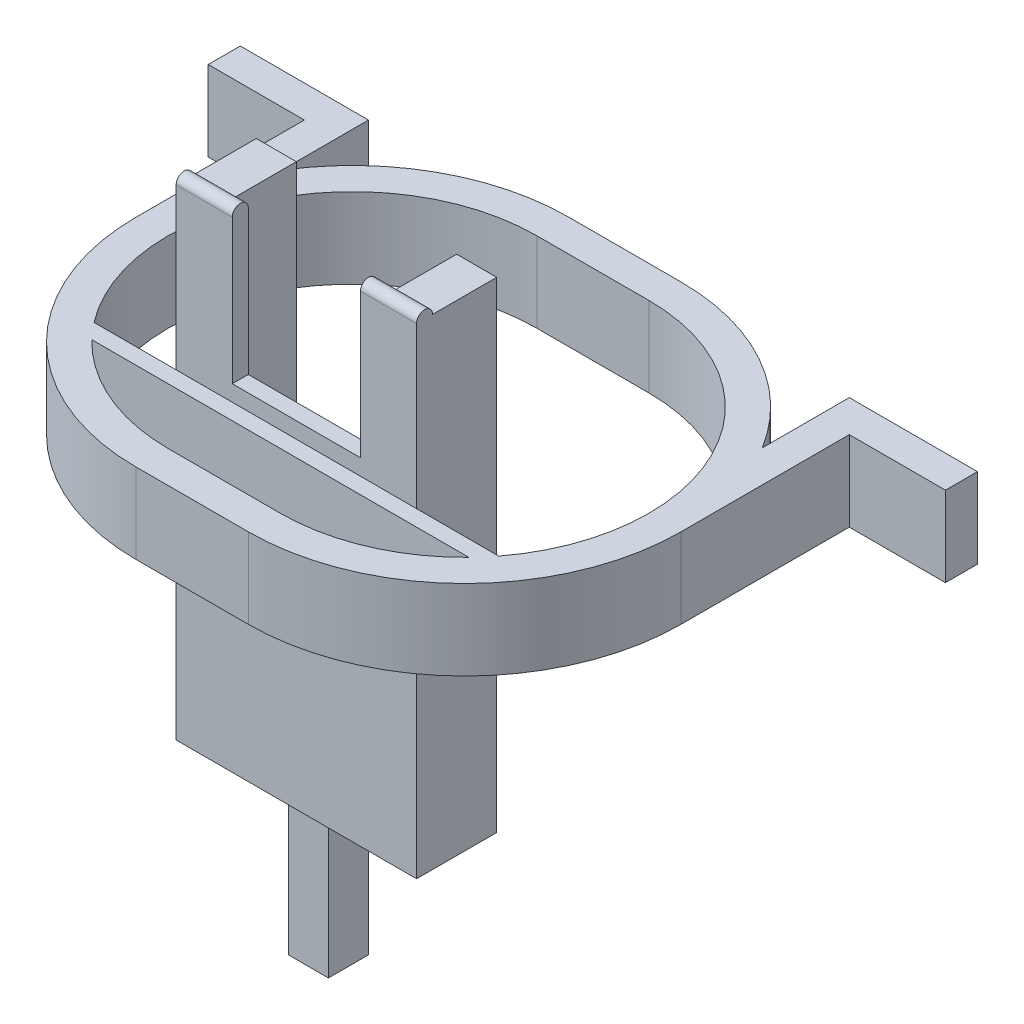
from build123d import *

# Parameters (mm, degrees)
EXTRUDE_1_DEPTH     = 10
SKETCH_3_W          = 30
SKETCH_3_H          = 60
EXTRUDE_2_DEPTH     = 10
SKETCH_7_R          = 1
EXTRUDE_4_DEPTH     = 30
SKETCH_6_W          = 16
SKETCH_6_H          = 49.282767792
CUT_EXTRUDE_2_DEPTH = 24
SKETCH_8_W          = 20
SKETCH_8_H          = 68.65426033
CUT_EXTRUDE_3_DEPTH = 8
SKETCH_10_W         = 4
SKETCH_10_H         = 4
SKETCH_16_W         = 5
SKETCH_16_H         = 5
EXTRUDE_5_DEPTH     = 2
SKETCH_17_W         = 4
SKETCH_17_H         = 25
EXTRUDE_6_DEPTH     = 10
SKETCH_18_W         = 12
SKETCH_18_H         = 4
EXTRUDE_7_DEPTH     = 10


with BuildPart() as part:
    # 草图2 → 凸台-拉伸1 (new body)
    with BuildSketch(Plane(origin=(0, 0, 0), x_dir=(1, 0, 0), z_dir=(0, 1, 0))):
        with BuildLine():
            Line((-7, 27), (7, 27))
            ThreePointArc((7, 27), (34, 0), (7, -27))
            Line((7, -27), (-7, -27))
            ThreePointArc((-7, -27), (-34, 0), (-7, 27))
        make_face()
        with BuildLine():
            Line((-7, 23), (7, 23))
            ThreePointArc((7, 23), (27.627651345, 10.173494975), (25.248287591, -14))
            Line((25.248287591, -14), (-25.248287591, -14))
            ThreePointArc((-25.248287591, -14), (-27.627651345, 10.173494975), (-7, 23))
        make_face(mode=Mode.SUBTRACT)
        with BuildLine():
            Line((-7, -23), (7, -23))
            ThreePointArc((7, -23), (15.972179222, -21.177818585), (23.522711642, -16))
            Line((23.522711642, -16), (-23.522711642, -16))
            ThreePointArc((-23.522711642, -16), (-15.972179222, -21.177818585), (-7, -23))
        make_face(mode=Mode.SUBTRACT)
    extrude(amount=EXTRUDE_1_DEPTH)

    # 草图3 → 凸台-拉伸2 (add)
    with BuildSketch(Plane(origin=(0, 0, 14), x_dir=(-1, 0, 0), z_dir=(0, 0, -1))):
        Rectangle(SKETCH_3_W, SKETCH_3_H)
    extrude(amount=EXTRUDE_2_DEPTH)

    # 草图7 → 凸台-拉伸4 (add)
    with BuildSketch(Plane.ZY.offset(15)):
        with Locations((13, 30)):
            Circle(SKETCH_7_R)
    extrude(amount=-EXTRUDE_4_DEPTH)

    # 草图6 → 切除-拉伸2 (cut, through all)
    with BuildSketch(Plane(origin=(0, 0, 4), x_dir=(-1, 0, 0), z_dir=(0, 0, -1))):
        with Locations((0, 36.641383896)):
            Rectangle(SKETCH_6_W, SKETCH_6_H)
    extrude(amount=-CUT_EXTRUDE_2_DEPTH, mode=Mode.SUBTRACT)

    # 草图8 → 切除-拉伸3 (cut)
    with BuildSketch(Plane(origin=(0, 0, 4), x_dir=(-1, 0, 0), z_dir=(0, 0, -1))):
        with Locations((0, -1.849037214)):
            Rectangle(SKETCH_8_W, SKETCH_8_H)
    extrude(amount=-CUT_EXTRUDE_3_DEPTH, mode=Mode.SUBTRACT)

    # 扫描2: sweep along a path in 草图12
    with BuildLine(Plane(origin=(0, 0, 12), x_dir=(-1, 0, 0), z_dir=(0, 0, -1))) as sweep_2_path:
        Line((-2.5, -8.196811454), (-2.5, -45.72167139))
    # 草图10 → 扫描2 (sweep)
    with BuildSketch(Plane.XZ.offset(30)):
        Polygon((-2.5, 12), (-2.5, 7.5), (2.5, 7.5), (2.5, 12), (2.5, 12.5), (-2.5, 12.5), align=None)
        with Locations((0, 10)):
            Rectangle(SKETCH_10_W, SKETCH_10_H, mode=Mode.SUBTRACT)
    sweep(path=sweep_2_path.line)

    # 草图16 → 凸台-拉伸5 (add)
    with BuildSketch(Plane.XZ.offset(45.72167139)):
        with Locations((0, 10)):
            Rectangle(SKETCH_16_W, SKETCH_16_H)
    extrude(amount=EXTRUDE_5_DEPTH)

    # 草图17 → 凸台-拉伸6 (add)
    with BuildSketch(Plane(origin=(0, 10, 0), x_dir=(1, 0, 0), z_dir=(0, 1, 0))):
        with Locations((-32, 12.5)):
            Rectangle(SKETCH_17_W, SKETCH_17_H)
        with Locations((32, 12.5)):
            Rectangle(SKETCH_17_W, SKETCH_17_H)
    extrude(amount=-EXTRUDE_6_DEPTH)

    # 草图18 → 凸台-拉伸7 (add)
    with BuildSketch(Plane(origin=(0, 10, 0), x_dir=(1, 0, 0), z_dir=(0, 1, 0))):
        with Locations((-40, 23)):
            Rectangle(SKETCH_18_W, SKETCH_18_H)
        with Locations((40, 23)):
            Rectangle(SKETCH_18_W, SKETCH_18_H)
    extrude(amount=-EXTRUDE_7_DEPTH)


solid = part.part
